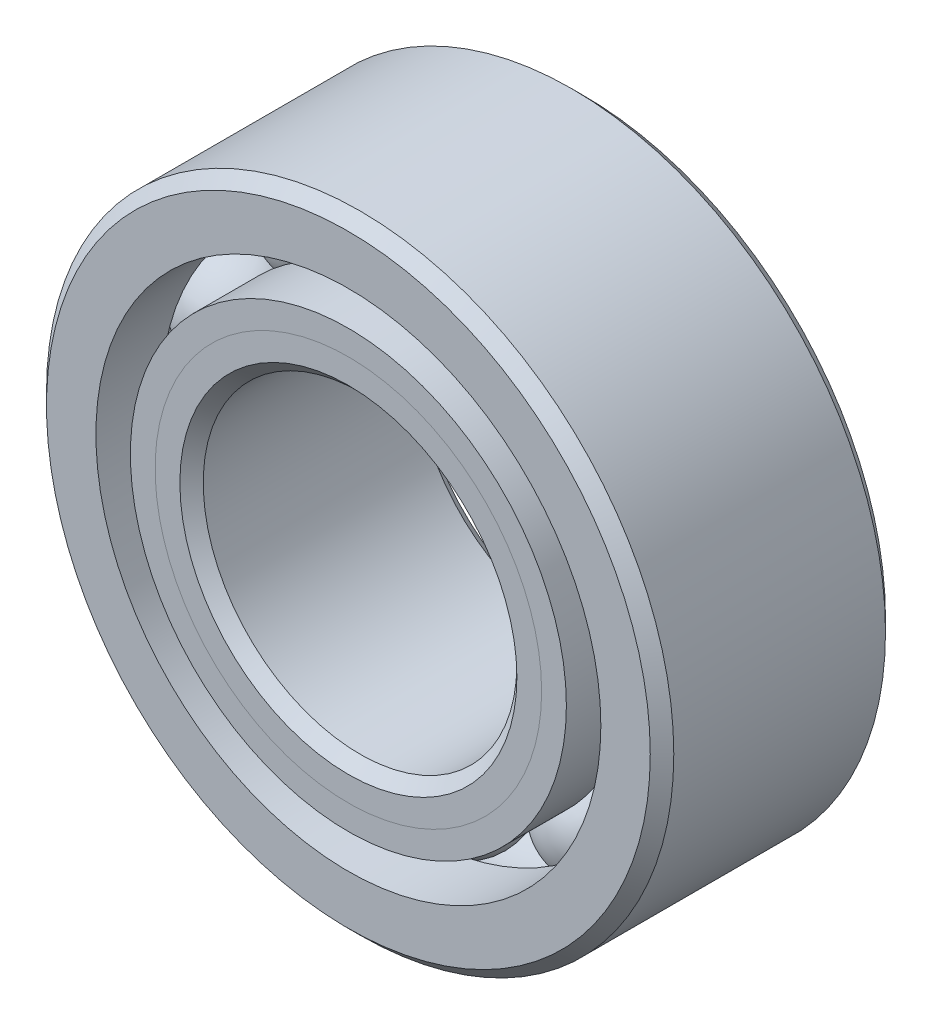
from build123d import *

# Parameters (mm, degrees)
CIRPATTERN1_COUNT = 10


with BuildPart() as part:
    # Sketch1 → Revolve1 (revolve)
    with BuildSketch(Plane(origin=(0, 0, 0), x_dir=(0, 0, -1), z_dir=(1, 0, 0))):
        with BuildLine():
            Line((1.0715625, 3.175), (-1.0715625, 3.175))
            Line((-1.0715625, 3.175), (-1.190625, 3.0559375))
            Line((-1.190625, 3.0559375), (-1.190625, 2.555700549))
            Line((-1.190625, 2.555700549), (-0.529166667, 2.555700549))
            ThreePointArc((-0.529166667, 2.555700549), (0, 2.938430721), (0.529166667, 2.555700549))
            Line((0.529166667, 2.555700549), (1.190625, 2.555700549))
            Line((1.190625, 2.555700549), (1.190625, 3.0559375))
            Line((1.190625, 3.0559375), (1.0715625, 3.175))
        make_face()
    revolve(axis=Axis((0, 0, 1.190625), (0, 0, -1)))


with BuildPart() as body_2:
    # Sketch2 → Revolve2 (revolve)
    with BuildSketch(Plane(origin=(0, 0, 0), x_dir=(0, 0, -1), z_dir=(1, 0, 0))):
        with BuildLine():
            Line((-1.190625, 2.206799451), (-0.529166667, 2.206799451))
            ThreePointArc((-0.529166667, 2.206799451), (-0.32653474, 1.929779714), (0, 1.824069279))
            Line((0, 1.824069279), (0, 1.70578464))
            Line((0, 1.70578464), (-0.940117595, 1.70578464))
            Line((-0.940117595, 1.70578464), (-1.190625, 1.956292045))
            Line((-1.190625, 1.956292045), (-1.190625, 2.206799451))
        make_face()
    revolve(axis=Axis((0, 0, 1.190625), (0, 0, -1)))


with BuildPart() as body_3:
    # Sketch3 → Revolve3 (revolve)
    with BuildSketch(Plane(origin=(0, 0, 0), x_dir=(0, 0, -1), z_dir=(1, 0, 0))):
        with BuildLine():
            Line((-1.190625, 1.956292045), (-0.940117595, 1.70578464))
            Line((-0.940117595, 1.70578464), (0, 1.70578464))
            Line((0, 1.70578464), (0, 1.824069279))
            ThreePointArc((0, 1.824069279), (0.32653474, 1.929779714), (0.529166667, 2.206799451))
            Line((0.529166667, 2.206799451), (1.190625, 2.206799451))
            Line((1.190625, 2.206799451), (1.190625, 1.7065625))
            Line((1.190625, 1.7065625), (1.0715625, 1.5875))
            Line((1.0715625, 1.5875), (-1.07234036, 1.5875))
            Line((-1.07234036, 1.5875), (-1.190625, 1.70578464))
            Line((-1.190625, 1.70578464), (-1.190625, 1.956292045))
        make_face()
    revolve(axis=Axis((0, 0, 1.190625), (0, 0, -1)))


with BuildPart() as body_4:
    # Sketch4 → Revolve4 (revolve)
    with BuildSketch(Plane(origin=(0, 0, 0), x_dir=(0, 0, -1), z_dir=(1, 0, 0))):
        with BuildLine():
            Line((-0.557180721, 2.38125), (0.557180721, 2.38125))
            ThreePointArc((0.557180721, 2.38125), (0, 2.938430721), (-0.557180721, 2.38125))
        make_face()
    revolve(axis=Axis((0, 2.38125, 0.557180721), (0, 0, -1)))


with BuildPart() as cirpattern1_1:
    # CirPattern1: pattern copy
    add(body_4.part.rotate(Axis((0, 0, -1.190625), (0, 0, 1)), 1 * 360 / CIRPATTERN1_COUNT))


with BuildPart() as cirpattern1_2:
    # CirPattern1: pattern copy
    add(body_4.part.rotate(Axis((0, 0, -1.190625), (0, 0, 1)), 2 * 360 / CIRPATTERN1_COUNT))


with BuildPart() as cirpattern1_3:
    # CirPattern1: pattern copy
    add(body_4.part.rotate(Axis((0, 0, -1.190625), (0, 0, 1)), 3 * 360 / CIRPATTERN1_COUNT))


with BuildPart() as cirpattern1_4:
    # CirPattern1: pattern copy
    add(body_4.part.rotate(Axis((0, 0, -1.190625), (0, 0, 1)), 4 * 360 / CIRPATTERN1_COUNT))


with BuildPart() as cirpattern1_5:
    # CirPattern1: pattern copy
    add(body_4.part.rotate(Axis((0, 0, -1.190625), (0, 0, 1)), 5 * 360 / CIRPATTERN1_COUNT))


with BuildPart() as cirpattern1_6:
    # CirPattern1: pattern copy
    add(body_4.part.rotate(Axis((0, 0, -1.190625), (0, 0, 1)), 6 * 360 / CIRPATTERN1_COUNT))


with BuildPart() as cirpattern1_7:
    # CirPattern1: pattern copy
    add(body_4.part.rotate(Axis((0, 0, -1.190625), (0, 0, 1)), 7 * 360 / CIRPATTERN1_COUNT))


with BuildPart() as cirpattern1_8:
    # CirPattern1: pattern copy
    add(body_4.part.rotate(Axis((0, 0, -1.190625), (0, 0, 1)), 8 * 360 / CIRPATTERN1_COUNT))


with BuildPart() as cirpattern1_9:
    # CirPattern1: pattern copy
    add(body_4.part.rotate(Axis((0, 0, -1.190625), (0, 0, 1)), 9 * 360 / CIRPATTERN1_COUNT))


solid = Compound([part.part, body_2.part, body_3.part, body_4.part, cirpattern1_1.part, cirpattern1_2.part, cirpattern1_3.part, cirpattern1_4.part, cirpattern1_5.part, cirpattern1_6.part, cirpattern1_7.part, cirpattern1_8.part, cirpattern1_9.part])
